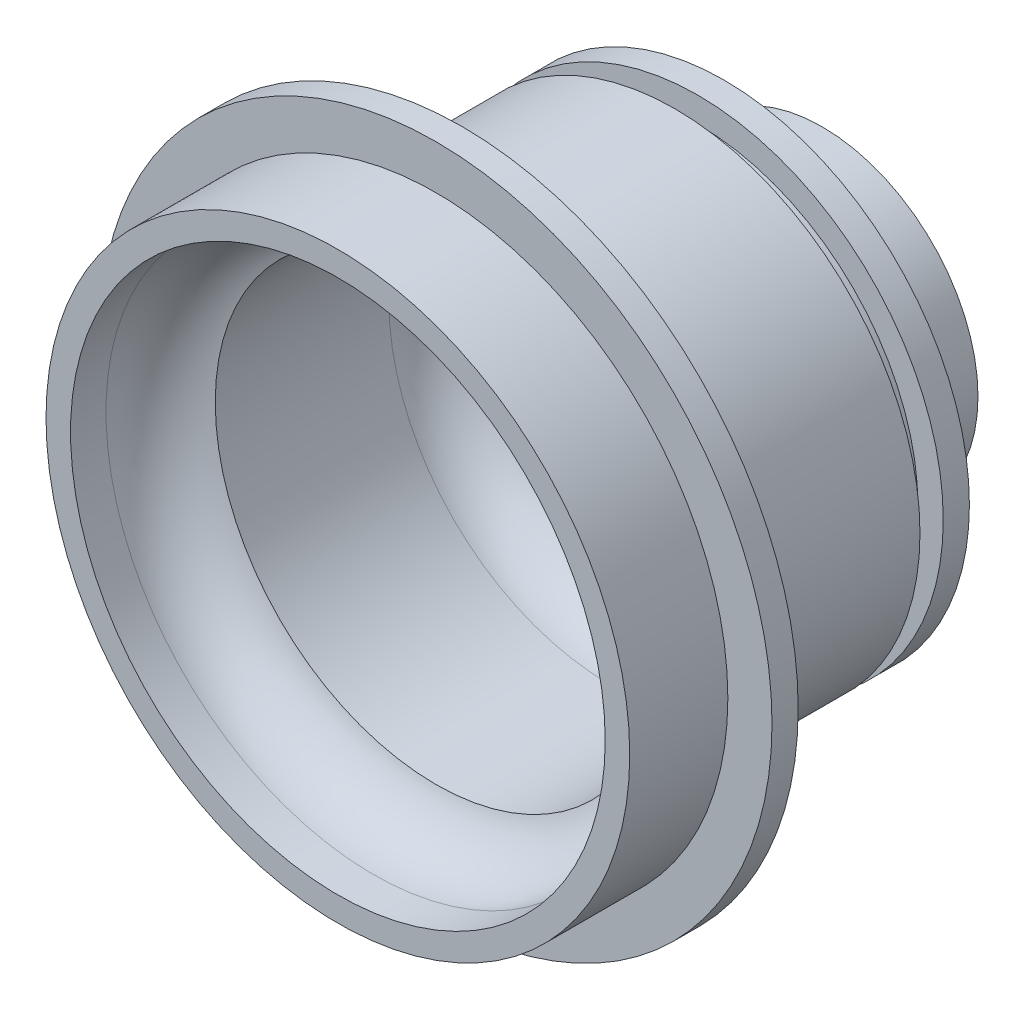
from build123d import *

# Parameters (mm, degrees)
FILLET2_R = 2


with BuildPart() as part:
    # Sketch2 → Revolve1 (revolve)
    with BuildSketch(Plane(origin=(0, 0, 0), x_dir=(0, 0, -1), z_dir=(1, 0, 0))):
        with BuildLine():
            Line((15.5224, 9.525), (9.5224, 9.525))
            Line((9.5224, 9.525), (9.5224, 15))
            Line((9.5224, 15), (7.9224, 15))
            Line((7.9224, 15), (7.9224, 13.45))
            Line((7.9224, 13.45), (6.5, 13.45))
            Line((6.5, 13.45), (6.5, 15))
            Line((6.5, 15), (-6.5, 15))
            Line((-6.5, 15), (-6.5, 20.55))
            Line((-6.5, 20.55), (-8.1, 20.55))
            Line((-8.1, 20.55), (-8.1, 17.85))
            Line((-8.1, 17.85), (-14.1, 17.85))
            Line((-14.1, 17.85), (-14.1, 16.35))
            Line((-14.1, 16.35), (-11.931122551, 16.35))
            ThreePointArc((-11.931122551, 16.35), (-9.543655274, 15.559361307), (-8.1, 13.5))
            Line((-8.1, 13.5), (2.5224, 13.5))
            ThreePointArc((2.5224, 13.5), (5.350827125, 12.328427125), (6.5224, 9.5))
            Line((6.5224, 9.5), (6.5224, 8.525))
            ThreePointArc((6.5224, 8.525), (7.108186438, 7.110786438), (8.5224, 6.525))
            Line((8.5224, 6.525), (15.5224, 6.525))
            Line((15.5224, 6.525), (15.5224, 9.525))
        make_face()
    revolve(axis=Axis((0, 0, 74.804360453), (0, 0, -1)))

    # Fillet2
    fillet2_edges = [part.edges().sort_by_distance(p)[0] for p in [
        (0, -9.525, -9.5224),
    ]]
    fillet(fillet2_edges, radius=FILLET2_R)


solid = part.part
